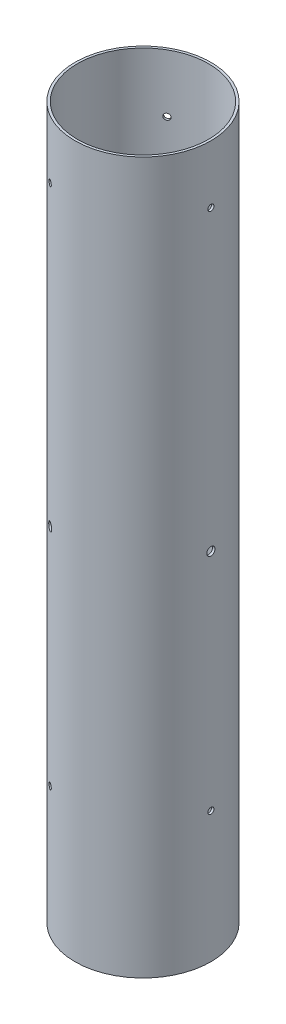
from build123d import *

# Parameters (mm, degrees)
SKETCH1_R                        = 39.624
SKETCH1_R_2                      = 38.227
BOSS_EXTRUDE1_DEPTH              = 414.3375
CUT_EXTRUDE1_START               = -1.438371
SKETCH2_R                        = 1.778
CUT_EXTRUDE1_DEPTH               = 1.438371
CIRPATTERN1_COUNT                = 3
PRESSURE_START                   = -1.471239
SKETCH3_R                        = 2.38125
PRESSURE_EQUALIZATION_HOLE_DEPTH = 1.471239
CIRPATTERN2_COUNT                = 3
SKETCH4_R                        = 1.7859375
CUT_EXTRUDE3_DEPTH               = 1.438742
CIRPATTERN3_COUNT                = 3


with BuildPart() as part:
    # Sketch1 → Boss-Extrude1 (new body)
    with BuildSketch(Plane(origin=(0, 0, 0), x_dir=(1, 0, 0), z_dir=(0, 1, 0))):
        Circle(SKETCH1_R)
        Circle(SKETCH1_R_2, mode=Mode.SUBTRACT)
    extrude(amount=BOSS_EXTRUDE1_DEPTH)

    # Sketch2 → Cut-Extrude1 (cut)
    with BuildSketch(Plane(origin=(-19.812, 0, 34.3153906), x_dir=(0, -1, 0), z_dir=(-0.5, 0, 0.866025404)).offset(CUT_EXTRUDE1_START)):
        with Locations((-76.2, 0)):
            Circle(SKETCH2_R)
    cut_extrude1 = extrude(amount=CUT_EXTRUDE1_DEPTH, mode=Mode.SUBTRACT)

    # CirPattern1: Cut-Extrude1 ×3 about axis
    cirpattern1_axis = Axis((0, -7.62, 0), (0, 1, 0))
    for i in range(1, CIRPATTERN1_COUNT):
        add(cut_extrude1.rotate(cirpattern1_axis, i * 360 / CIRPATTERN1_COUNT), mode=Mode.SUBTRACT)

    # Sketch3 → Pressure Equalization Hole (cut)
    with BuildSketch(Plane(origin=(-19.812, 0, 34.3153906), x_dir=(0, -1, 0), z_dir=(-0.5, 0, 0.866025404)).offset(PRESSURE_START)):
        with Locations((-207.16875, 0)):
            Circle(SKETCH3_R)
    pressure_equalization_hole = extrude(amount=PRESSURE_EQUALIZATION_HOLE_DEPTH, mode=Mode.SUBTRACT)

    # CirPattern2: Pressure Equalization Hole ×3 about axis
    cirpattern2_axis = Axis((0, -7.62, 0), (0, 1, 0))
    for i in range(1, CIRPATTERN2_COUNT):
        add(pressure_equalization_hole.rotate(cirpattern2_axis, i * 360 / CIRPATTERN2_COUNT), mode=Mode.SUBTRACT)

    # Sketch4 → Cut-Extrude3 (cut)
    with BuildSketch(Plane(origin=(39.624, 0, 0), x_dir=(0, -1, 0), z_dir=(-1, 0, 0))):
        with Locations((-380.5301, 0)):
            Circle(SKETCH4_R)
    cut_extrude3 = extrude(amount=CUT_EXTRUDE3_DEPTH, mode=Mode.SUBTRACT)

    # CirPattern3: Cut-Extrude3 ×3 about axis
    cirpattern3_axis = Axis((0, -7.62, 0), (0, 1, 0))
    for i in range(1, CIRPATTERN3_COUNT):
        add(cut_extrude3.rotate(cirpattern3_axis, i * 360 / CIRPATTERN3_COUNT), mode=Mode.SUBTRACT)


solid = part.part
